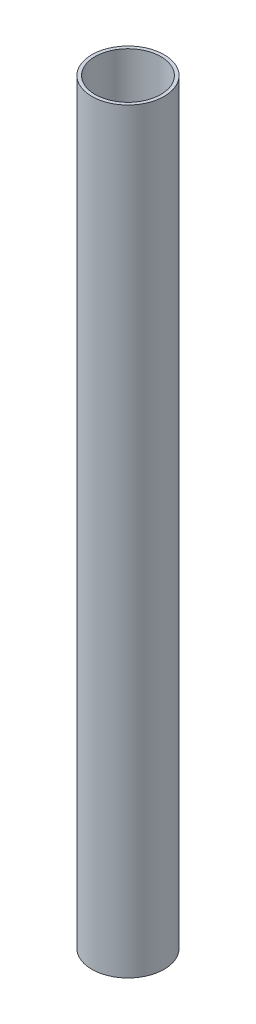
from build123d import *

# Parameters (mm, degrees)
SKETCH_1_R      = 11
SKETCH_1_R_2    = 10
EXTRUDE_1_DEPTH = 230


with BuildPart() as part:
    # 草图1 → 凸台-拉伸1 (new body)
    with BuildSketch(Plane(origin=(0, 0, 0), x_dir=(1, 0, 0), z_dir=(0, 1, 0))):
        Circle(SKETCH_1_R)
        Circle(SKETCH_1_R_2, mode=Mode.SUBTRACT)
    extrude(amount=EXTRUDE_1_DEPTH)


solid = part.part
